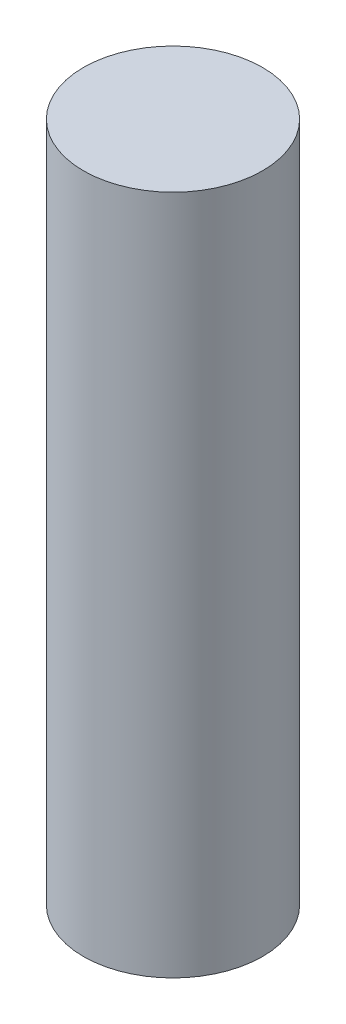
from build123d import *

# Parameters (mm, degrees)
SKETCH1_R           = 12.7
BOSS_EXTRUDE1_DEPTH = 96.52


with BuildPart() as part:
    # Sketch1 → Boss-Extrude1 (new body)
    with BuildSketch(Plane(origin=(0, 0, 0), x_dir=(1, 0, 0), z_dir=(0, 1, 0))):
        Circle(SKETCH1_R)
    extrude(amount=BOSS_EXTRUDE1_DEPTH)


solid = part.part
